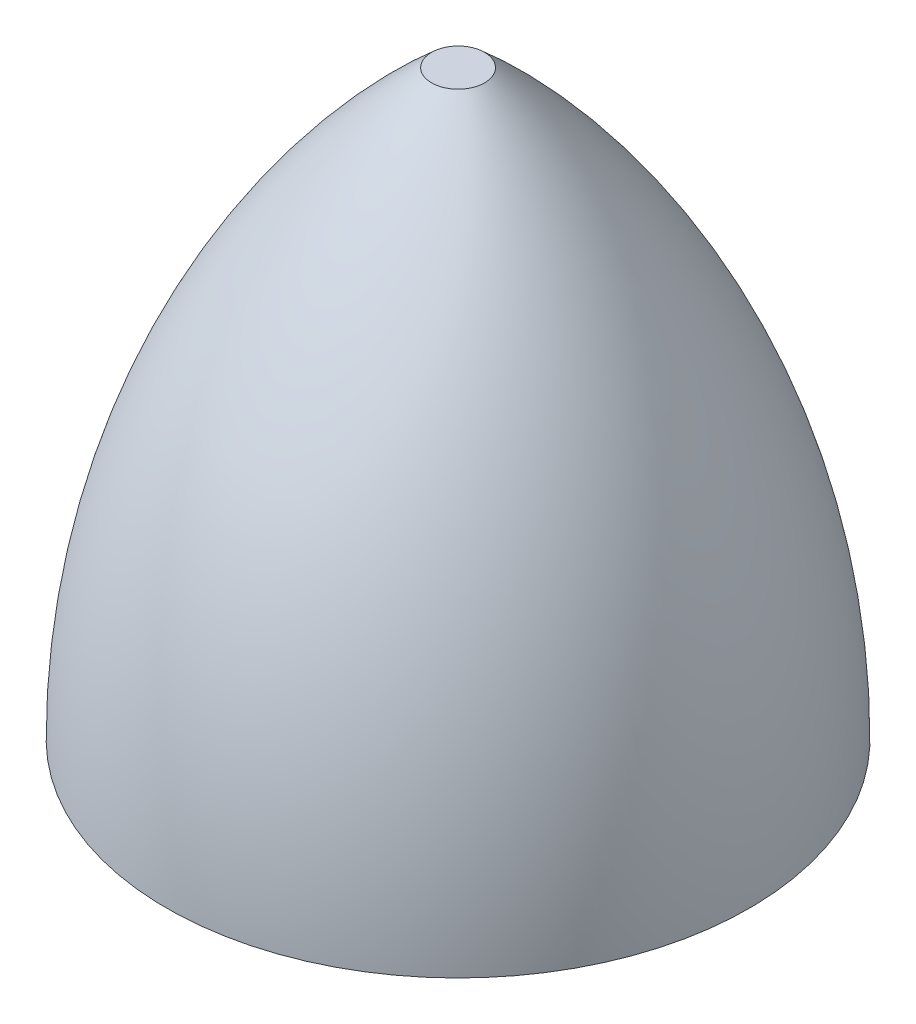
from build123d import *


with BuildPart() as part:
    # Esboço1 → Revolução2 (revolve)
    with BuildSketch(Plane.XY):
        with BuildLine():
            Line((0, 0), (110, 0))
            ThreePointArc((110, 0), (83.827011419, 120.830459736), (10, 220))
            Line((10, 220), (0, 220))
            Line((0, 220), (0, 0))
        make_face()
    revolve(axis=Axis((0, 0, 0), (0, 1, 0)))


solid = part.part
